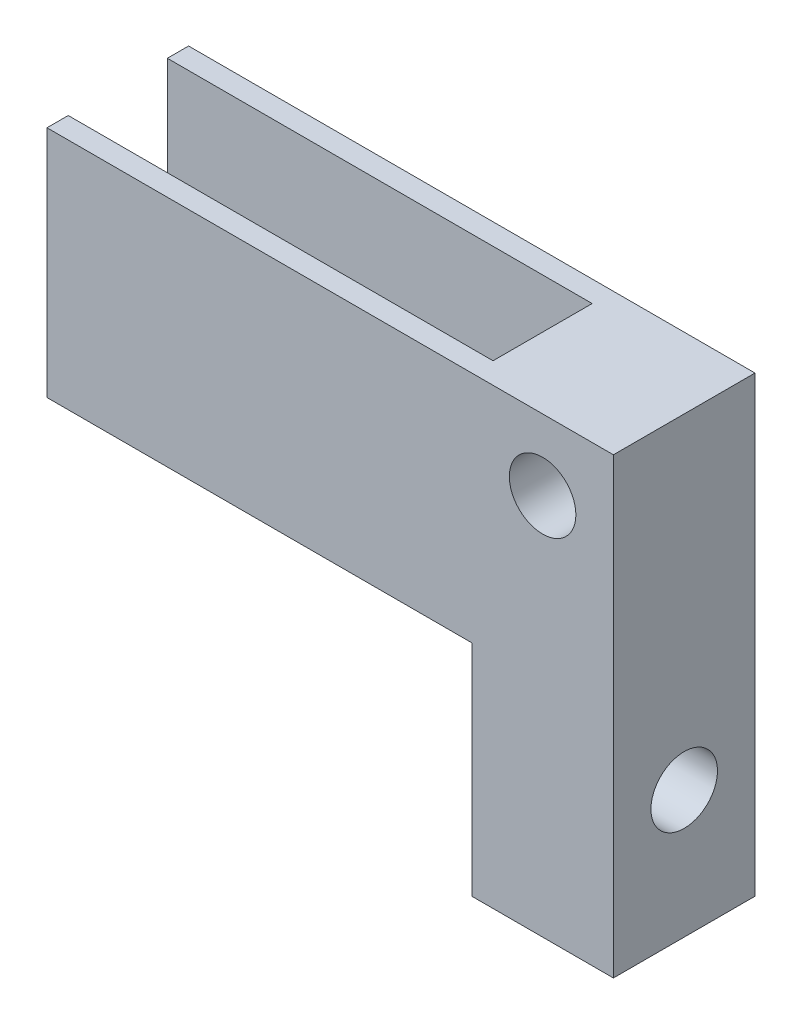
from build123d import *

# Parameters (mm, degrees)
SKETCH2_W           = 10
SKETCH2_H           = 50
BOSS_EXTRUDE1_DEPTH = 10
SKETCH6_R           = 2.35
CUT_EXTRUDE3_DEPTH  = 11
SKETCH7_R           = 2.35
CUT_EXTRUDE4_DEPTH  = 11
SKETCH8_W           = 1.5
SKETCH8_H           = 21
BOSS_EXTRUDE2_DEPTH = 30
SKETCH9_W           = 52.99414334
SKETCH9_H           = 19.059793282
CUT_EXTRUDE5_DEPTH  = 11


with BuildPart() as part:
    # Sketch2 → Boss-Extrude1 (new body)
    with BuildSketch(Plane.XY):
        with Locations((5, 25)):
            Rectangle(SKETCH2_W, SKETCH2_H)
    extrude(amount=BOSS_EXTRUDE1_DEPTH)

    # Sketch6 → Cut-Extrude3 (cut, through all)
    with BuildSketch(Plane.XY.offset(10)):
        with Locations((5, 27)):
            Circle(SKETCH6_R)
    extrude(amount=-CUT_EXTRUDE3_DEPTH, mode=Mode.SUBTRACT)

    # Sketch7 → Cut-Extrude4 (cut, through all)
    with BuildSketch(Plane.ZY):
        with Locations((5, 41)):
            Circle(SKETCH7_R)
        with Locations((5, 9)):
            Circle(SKETCH7_R)
    extrude(amount=-CUT_EXTRUDE4_DEPTH, mode=Mode.SUBTRACT)

    # Sketch8 → Boss-Extrude2 (add)
    with BuildSketch(Plane.ZY):
        with Locations((9.25, 26)):
            Rectangle(SKETCH8_W, SKETCH8_H)
        with Locations((0.75, 26)):
            Rectangle(SKETCH8_W, SKETCH8_H)
    extrude(amount=BOSS_EXTRUDE2_DEPTH)

    # Sketch9 → Cut-Extrude5 (cut, through all)
    with BuildSketch(Plane.XY.offset(10)):
        with Locations((-7.642110933, 41.529896641)):
            Rectangle(SKETCH9_W, SKETCH9_H)
    extrude(amount=-CUT_EXTRUDE5_DEPTH, mode=Mode.SUBTRACT)


solid = part.part
